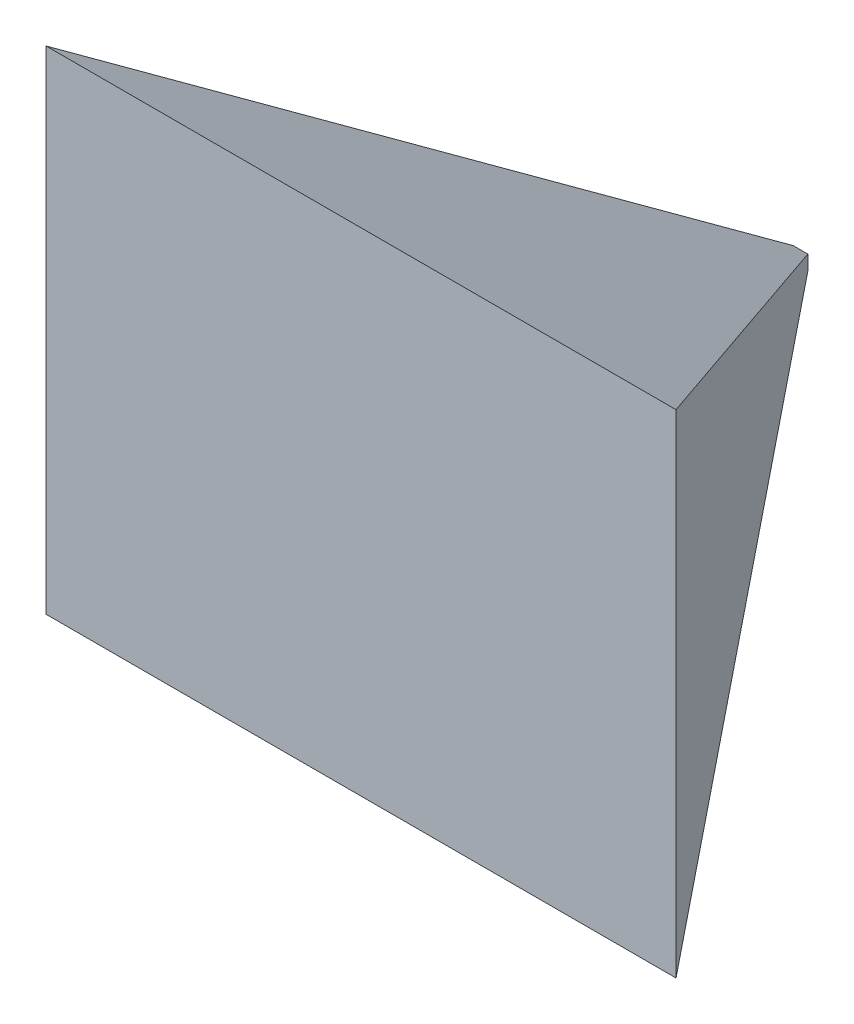
from build123d import *

# Parameters (mm, degrees)
SKETCH1_W = 10
SKETCH1_H = 10
SKETCH2_W = 430
SKETCH2_H = 336


with BuildPart() as part:
    # Sketch1 → Loft1 section 0
    with BuildSketch(Plane.XY):
        Rectangle(SKETCH1_W, SKETCH1_H)
    # Sketch2 → Loft1 section 1
    with BuildSketch(Plane.XY.offset(300)):
        Rectangle(SKETCH2_W, SKETCH2_H)
    loft()


solid = part.part
